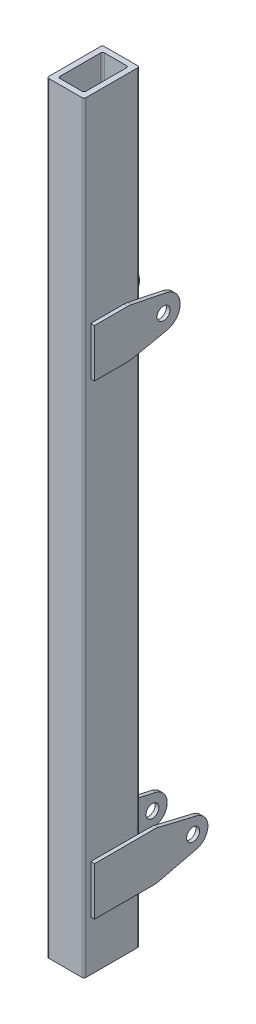
from build123d import *

# Parameters (mm, degrees)
BOSS_EXTRUDE1_DEPTH = 2060
SKETCH2_R           = 17.5
BOSS_EXTRUDE2_DEPTH = 10
SKETCH4_R           = 17.5
BOSS_EXTRUDE3_DEPTH = 10


with BuildPart() as part:
    # Sketch1 → Boss-Extrude1 (new body)
    with BuildSketch(Plane(origin=(0, 0, 0), x_dir=(1, 0, 0), z_dir=(0, 1, 0))):
        with BuildLine():
            Line((-45, -75), (45, -75))
            ThreePointArc((45, -75), (48.535533906, -73.535533906), (50, -70))
            Line((50, -70), (50, 70))
            ThreePointArc((50, 70), (48.535533906, 73.535533906), (45, 75))
            Line((45, 75), (-45, 75))
            ThreePointArc((-45, 75), (-48.535533906, 73.535533906), (-50, 70))
            Line((-50, 70), (-50, -70))
            ThreePointArc((-50, -70), (-48.535533906, -73.535533906), (-45, -75))
        make_face()
        with BuildLine():
            Line((-30, -60), (30, -60))
            ThreePointArc((30, -60), (33.535533906, -58.535533906), (35, -55))
            Line((35, -55), (35, 55))
            ThreePointArc((35, 55), (33.535533906, 58.535533906), (30, 60))
            Line((30, 60), (-30, 60))
            ThreePointArc((-30, 60), (-33.535533906, 58.535533906), (-35, 55))
            Line((-35, 55), (-35, -55))
            ThreePointArc((-35, -55), (-33.535533906, -58.535533906), (-30, -60))
        make_face(mode=Mode.SUBTRACT)
    extrude(amount=BOSS_EXTRUDE1_DEPTH)

    # Sketch2 → Boss-Extrude2 (add)
    with BuildSketch(Plane(origin=(50, 0, 0), x_dir=(0, 0, -1), z_dir=(1, 0, 0))):
        with BuildLine():
            Line((43.395359238, 1396.045447211), (139.154011501, 1415.94090249))
            ThreePointArc((139.154011501, 1415.94090249), (175, 1460), (139.154011501, 1504.05909751))
            Line((139.154011501, 1504.05909751), (43.395359238, 1523.954552789))
            ThreePointArc((43.395359238, 1523.954552789), (38.336590995, 1524.737951503), (33.224235348, 1525))
            Line((33.224235348, 1525), (-56.636474138, 1525))
            Line((-56.636474138, 1525), (-56.636474138, 1460))
            Line((-56.636474138, 1460), (-56.636474138, 1395))
            Line((-56.636474138, 1395), (33.224235348, 1395))
            ThreePointArc((33.224235348, 1395), (38.336590995, 1395.262048497), (43.395359238, 1396.045447211))
        make_face()
        with Locations((130, 1460)):
            Circle(SKETCH2_R, mode=Mode.SUBTRACT)
        with BuildLine():
            Line((-56.636474138, 200), (-56.636474138, 265))
            Line((-56.636474138, 265), (104.432577767, 265))
            ThreePointArc((104.432577767, 265), (110.295724617, 264.655045152), (116.07797063, 263.624940361))
            Line((116.07797063, 263.624940361), (219.31631429, 238.899952288))
            ThreePointArc((219.31631429, 238.899952288), (250, 200), (219.31631429, 161.100047712))
            Line((219.31631429, 161.100047712), (116.07797063, 136.375059639))
            ThreePointArc((116.07797063, 136.375059639), (110.295724617, 135.344954848), (104.432577767, 135))
            Line((104.432577767, 135), (-56.636474138, 135))
            Line((-56.636474138, 135), (-56.636474138, 200))
        make_face()
        with Locations((210, 200)):
            Circle(SKETCH2_R, mode=Mode.SUBTRACT)
    extrude(amount=BOSS_EXTRUDE2_DEPTH)

    # Sketch4 → Boss-Extrude3 (add)
    with BuildSketch(Plane.ZY.offset(50)):
        with BuildLine():
            Line((-219.31631429, 238.899952288), (-109.901430019, 263.757549946))
            ThreePointArc((-109.901430019, 263.757549946), (-104.397629265, 264.688416645), (-98.824367082, 265))
            Line((-98.824367082, 265), (56.64, 265))
            Line((56.64, 265), (56.64, 200))
            Line((56.64, 200), (56.64, 135))
            Line((56.64, 135), (-98.824367082, 135))
            ThreePointArc((-98.824367082, 135), (-104.397629265, 135.311583355), (-109.901430019, 136.242450054))
            Line((-109.901430019, 136.242450054), (-219.31631429, 161.100047712))
            ThreePointArc((-219.31631429, 161.100047712), (-250, 200), (-219.31631429, 238.899952288))
        make_face()
        with Locations((-210, 200)):
            Circle(SKETCH4_R, mode=Mode.SUBTRACT)
        with BuildLine():
            Line((56.64, 1460), (56.64, 1525))
            Line((56.64, 1525), (-33.220885504, 1525))
            ThreePointArc((-33.220885504, 1525), (-38.333067886, 1524.737969312), (-43.391668321, 1523.954623652))
            Line((-43.391668321, 1523.954623652), (-139.154011501, 1504.05909751))
            ThreePointArc((-139.154011501, 1504.05909751), (-175, 1460), (-139.154011501, 1415.94090249))
            Line((-139.154011501, 1415.94090249), (-43.391668321, 1396.045376348))
            ThreePointArc((-43.391668321, 1396.045376348), (-38.333067886, 1395.262030688), (-33.220885504, 1395))
            Line((-33.220885504, 1395), (56.64, 1395))
            Line((56.64, 1395), (56.64, 1460))
        make_face()
        with Locations((-130, 1460)):
            Circle(SKETCH4_R, mode=Mode.SUBTRACT)
    extrude(amount=BOSS_EXTRUDE3_DEPTH)


solid = part.part
